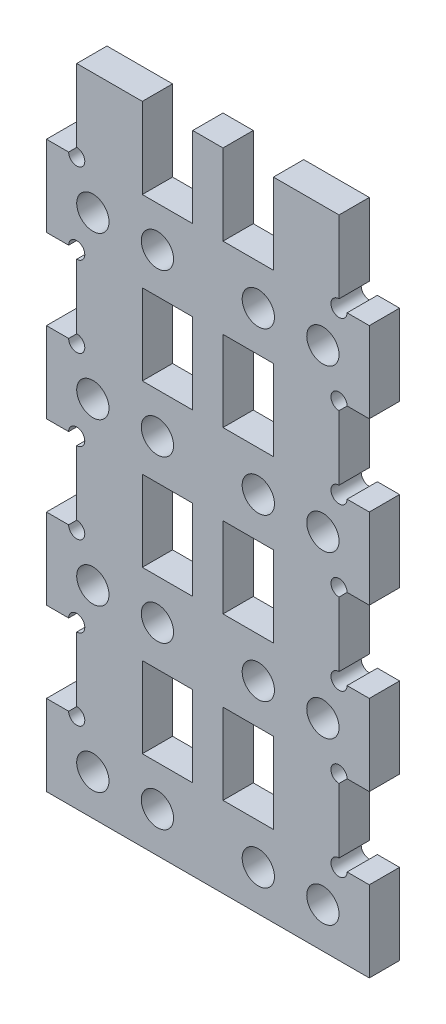
from build123d import *

# Parameters (mm, degrees)
EXTRUDE_1_DEPTH     = 3
SKETCH_2_W          = 5
SKETCH_2_H          = 8
CUT_EXTRUDE_1_DEPTH = 3
SKETCH_3_R          = 1.6
CUT_EXTRUDE_2_DEPTH = 3
CUT_EXTRUDE_3_REACH = 5
SKETCH_5_R          = 1.6
CUT_EXTRUDE_4_REACH = 5
SKETCH_6_R          = 0.8


with BuildPart() as part:
    # 草图1 → 凸台-拉伸1 (new body)
    with BuildSketch(Plane.XY):
        Polygon((16, 0), (-16, 0), (-16, 8), (-13, 8), (-13, 16), (-16, 16), (-16, 24), (-13, 24), (-13, 32), (-16, 32), (-16, 40), (-13, 40), (-13, 48), (-16, 48), (-16, 56), (-13, 56), (-13, 64), (13, 64), (13, 56), (16, 56), (16, 48), (13, 48), (13, 40), (16, 40), (16, 32), (13, 32), (13, 24), (16, 24), (16, 16), (13, 16), (13, 8), (16, 8), align=None)
    extrude(amount=EXTRUDE_1_DEPTH)

    # 草图2 → 切除-拉伸1 (cut)
    with BuildSketch(Plane.XY.offset(3)):
        with Locations((-4, 28)):
            Rectangle(SKETCH_2_W, SKETCH_2_H)
        with Locations((-4, 12)):
            Rectangle(SKETCH_2_W, SKETCH_2_H)
        with Locations((4, 28)):
            Rectangle(SKETCH_2_W, SKETCH_2_H)
        with Locations((-4, 44)):
            Rectangle(SKETCH_2_W, SKETCH_2_H)
        with Locations((4, 44)):
            Rectangle(SKETCH_2_W, SKETCH_2_H)
        with Locations((4, 12)):
            Rectangle(SKETCH_2_W, SKETCH_2_H)
        with Locations((4, 60)):
            Rectangle(SKETCH_2_W, SKETCH_2_H)
        with Locations((-4, 60)):
            Rectangle(SKETCH_2_W, SKETCH_2_H)
    extrude(amount=-CUT_EXTRUDE_1_DEPTH, mode=Mode.SUBTRACT)

    # 草图3 → 切除-拉伸2 (cut)
    with BuildSketch(Plane.XY.offset(3)):
        with Locations((-11.4, 4)):
            Circle(SKETCH_3_R)
        with Locations((11.4, 4)):
            Circle(SKETCH_3_R)
        with Locations((-11.4, 20)):
            Circle(SKETCH_3_R)
        with Locations((11.4, 20)):
            Circle(SKETCH_3_R)
        with Locations((-11.4, 36)):
            Circle(SKETCH_3_R)
        with Locations((11.4, 36)):
            Circle(SKETCH_3_R)
        with Locations((-11.4, 52)):
            Circle(SKETCH_3_R)
        with Locations((11.4, 52)):
            Circle(SKETCH_3_R)
    extrude(amount=-CUT_EXTRUDE_2_DEPTH, mode=Mode.SUBTRACT)

    # 草图5 → 切除-拉伸3 (cut, up to next)
    with BuildSketch(Plane.XY.offset(3), mode=Mode.PRIVATE) as cut_extrude_3_sk1:
        with Locations((-5, 4)):
            Circle(SKETCH_5_R)
    cut_extrude_3_tool1 = extrude(cut_extrude_3_sk1.sketch, amount=-CUT_EXTRUDE_3_REACH, mode=Mode.PRIVATE) & part.part
    add(cut_extrude_3_tool1.solids().sort_by_distance((-5, 4, 3))[0], mode=Mode.SUBTRACT)
    # 草图5 → 切除-拉伸3 (cut, up to next)
    with BuildSketch(Plane.XY.offset(3), mode=Mode.PRIVATE) as cut_extrude_3_sk2:
        with Locations((5, 4)):
            Circle(SKETCH_5_R)
    cut_extrude_3_tool2 = extrude(cut_extrude_3_sk2.sketch, amount=-CUT_EXTRUDE_3_REACH, mode=Mode.PRIVATE) & part.part
    add(cut_extrude_3_tool2.solids().sort_by_distance((5, 4, 3))[0], mode=Mode.SUBTRACT)
    # 草图5 → 切除-拉伸3 (cut, up to next)
    with BuildSketch(Plane.XY.offset(3), mode=Mode.PRIVATE) as cut_extrude_3_sk3:
        with Locations((-5, 20)):
            Circle(SKETCH_5_R)
    cut_extrude_3_tool3 = extrude(cut_extrude_3_sk3.sketch, amount=-CUT_EXTRUDE_3_REACH, mode=Mode.PRIVATE) & part.part
    add(cut_extrude_3_tool3.solids().sort_by_distance((-5, 20, 3))[0], mode=Mode.SUBTRACT)
    # 草图5 → 切除-拉伸3 (cut, up to next)
    with BuildSketch(Plane.XY.offset(3), mode=Mode.PRIVATE) as cut_extrude_3_sk4:
        with Locations((5, 20)):
            Circle(SKETCH_5_R)
    cut_extrude_3_tool4 = extrude(cut_extrude_3_sk4.sketch, amount=-CUT_EXTRUDE_3_REACH, mode=Mode.PRIVATE) & part.part
    add(cut_extrude_3_tool4.solids().sort_by_distance((5, 20, 3))[0], mode=Mode.SUBTRACT)
    # 草图5 → 切除-拉伸3 (cut, up to next)
    with BuildSketch(Plane.XY.offset(3), mode=Mode.PRIVATE) as cut_extrude_3_sk5:
        with Locations((-5, 36)):
            Circle(SKETCH_5_R)
    cut_extrude_3_tool5 = extrude(cut_extrude_3_sk5.sketch, amount=-CUT_EXTRUDE_3_REACH, mode=Mode.PRIVATE) & part.part
    add(cut_extrude_3_tool5.solids().sort_by_distance((-5, 36, 3))[0], mode=Mode.SUBTRACT)
    # 草图5 → 切除-拉伸3 (cut, up to next)
    with BuildSketch(Plane.XY.offset(3), mode=Mode.PRIVATE) as cut_extrude_3_sk6:
        with Locations((5, 36)):
            Circle(SKETCH_5_R)
    cut_extrude_3_tool6 = extrude(cut_extrude_3_sk6.sketch, amount=-CUT_EXTRUDE_3_REACH, mode=Mode.PRIVATE) & part.part
    add(cut_extrude_3_tool6.solids().sort_by_distance((5, 36, 3))[0], mode=Mode.SUBTRACT)
    # 草图5 → 切除-拉伸3 (cut, up to next)
    with BuildSketch(Plane.XY.offset(3), mode=Mode.PRIVATE) as cut_extrude_3_sk7:
        with Locations((-5, 52)):
            Circle(SKETCH_5_R)
    cut_extrude_3_tool7 = extrude(cut_extrude_3_sk7.sketch, amount=-CUT_EXTRUDE_3_REACH, mode=Mode.PRIVATE) & part.part
    add(cut_extrude_3_tool7.solids().sort_by_distance((-5, 52, 3))[0], mode=Mode.SUBTRACT)
    # 草图5 → 切除-拉伸3 (cut, up to next)
    with BuildSketch(Plane.XY.offset(3), mode=Mode.PRIVATE) as cut_extrude_3_sk8:
        with Locations((5, 52)):
            Circle(SKETCH_5_R)
    cut_extrude_3_tool8 = extrude(cut_extrude_3_sk8.sketch, amount=-CUT_EXTRUDE_3_REACH, mode=Mode.PRIVATE) & part.part
    add(cut_extrude_3_tool8.solids().sort_by_distance((5, 52, 3))[0], mode=Mode.SUBTRACT)

    # 草图6 → 切除-拉伸4 (cut, up to next)
    with BuildSketch(Plane.XY.offset(3), mode=Mode.PRIVATE) as cut_extrude_4_sk1:
        with Locations((-13, 8)):
            Circle(SKETCH_6_R)
    cut_extrude_4_tool1 = extrude(cut_extrude_4_sk1.sketch, amount=-CUT_EXTRUDE_4_REACH, mode=Mode.PRIVATE) & part.part
    add(cut_extrude_4_tool1.solids().sort_by_distance((-13, 8, 3))[0], mode=Mode.SUBTRACT)
    # 草图6 → 切除-拉伸4 (cut, up to next)
    with BuildSketch(Plane.XY.offset(3), mode=Mode.PRIVATE) as cut_extrude_4_sk2:
        with Locations((-13, 16)):
            Circle(SKETCH_6_R)
    cut_extrude_4_tool2 = extrude(cut_extrude_4_sk2.sketch, amount=-CUT_EXTRUDE_4_REACH, mode=Mode.PRIVATE) & part.part
    add(cut_extrude_4_tool2.solids().sort_by_distance((-13, 16, 3))[0], mode=Mode.SUBTRACT)
    # 草图6 → 切除-拉伸4 (cut, up to next)
    with BuildSketch(Plane.XY.offset(3), mode=Mode.PRIVATE) as cut_extrude_4_sk3:
        with Locations((-13, 24)):
            Circle(SKETCH_6_R)
    cut_extrude_4_tool3 = extrude(cut_extrude_4_sk3.sketch, amount=-CUT_EXTRUDE_4_REACH, mode=Mode.PRIVATE) & part.part
    add(cut_extrude_4_tool3.solids().sort_by_distance((-13, 24, 3))[0], mode=Mode.SUBTRACT)
    # 草图6 → 切除-拉伸4 (cut, up to next)
    with BuildSketch(Plane.XY.offset(3), mode=Mode.PRIVATE) as cut_extrude_4_sk4:
        with Locations((-13, 32)):
            Circle(SKETCH_6_R)
    cut_extrude_4_tool4 = extrude(cut_extrude_4_sk4.sketch, amount=-CUT_EXTRUDE_4_REACH, mode=Mode.PRIVATE) & part.part
    add(cut_extrude_4_tool4.solids().sort_by_distance((-13, 32, 3))[0], mode=Mode.SUBTRACT)
    # 草图6 → 切除-拉伸4 (cut, up to next)
    with BuildSketch(Plane.XY.offset(3), mode=Mode.PRIVATE) as cut_extrude_4_sk5:
        with Locations((-13, 40)):
            Circle(SKETCH_6_R)
    cut_extrude_4_tool5 = extrude(cut_extrude_4_sk5.sketch, amount=-CUT_EXTRUDE_4_REACH, mode=Mode.PRIVATE) & part.part
    add(cut_extrude_4_tool5.solids().sort_by_distance((-13, 40, 3))[0], mode=Mode.SUBTRACT)
    # 草图6 → 切除-拉伸4 (cut, up to next)
    with BuildSketch(Plane.XY.offset(3), mode=Mode.PRIVATE) as cut_extrude_4_sk6:
        with Locations((-13, 48)):
            Circle(SKETCH_6_R)
    cut_extrude_4_tool6 = extrude(cut_extrude_4_sk6.sketch, amount=-CUT_EXTRUDE_4_REACH, mode=Mode.PRIVATE) & part.part
    add(cut_extrude_4_tool6.solids().sort_by_distance((-13, 48, 3))[0], mode=Mode.SUBTRACT)
    # 草图6 → 切除-拉伸4 (cut, up to next)
    with BuildSketch(Plane.XY.offset(3), mode=Mode.PRIVATE) as cut_extrude_4_sk7:
        with Locations((-13, 56)):
            Circle(SKETCH_6_R)
    cut_extrude_4_tool7 = extrude(cut_extrude_4_sk7.sketch, amount=-CUT_EXTRUDE_4_REACH, mode=Mode.PRIVATE) & part.part
    add(cut_extrude_4_tool7.solids().sort_by_distance((-13, 56, 3))[0], mode=Mode.SUBTRACT)
    # 草图6 → 切除-拉伸4 (cut, up to next)
    with BuildSketch(Plane.XY.offset(3), mode=Mode.PRIVATE) as cut_extrude_4_sk8:
        with Locations((13, 8)):
            Circle(SKETCH_6_R)
    cut_extrude_4_tool8 = extrude(cut_extrude_4_sk8.sketch, amount=-CUT_EXTRUDE_4_REACH, mode=Mode.PRIVATE) & part.part
    add(cut_extrude_4_tool8.solids().sort_by_distance((13, 8, 3))[0], mode=Mode.SUBTRACT)
    # 草图6 → 切除-拉伸4 (cut, up to next)
    with BuildSketch(Plane.XY.offset(3), mode=Mode.PRIVATE) as cut_extrude_4_sk9:
        with Locations((13, 16)):
            Circle(SKETCH_6_R)
    cut_extrude_4_tool9 = extrude(cut_extrude_4_sk9.sketch, amount=-CUT_EXTRUDE_4_REACH, mode=Mode.PRIVATE) & part.part
    add(cut_extrude_4_tool9.solids().sort_by_distance((13, 16, 3))[0], mode=Mode.SUBTRACT)
    # 草图6 → 切除-拉伸4 (cut, up to next)
    with BuildSketch(Plane.XY.offset(3), mode=Mode.PRIVATE) as cut_extrude_4_sk10:
        with Locations((13, 24)):
            Circle(SKETCH_6_R)
    cut_extrude_4_tool10 = extrude(cut_extrude_4_sk10.sketch, amount=-CUT_EXTRUDE_4_REACH, mode=Mode.PRIVATE) & part.part
    add(cut_extrude_4_tool10.solids().sort_by_distance((13, 24, 3))[0], mode=Mode.SUBTRACT)
    # 草图6 → 切除-拉伸4 (cut, up to next)
    with BuildSketch(Plane.XY.offset(3), mode=Mode.PRIVATE) as cut_extrude_4_sk11:
        with Locations((13, 32)):
            Circle(SKETCH_6_R)
    cut_extrude_4_tool11 = extrude(cut_extrude_4_sk11.sketch, amount=-CUT_EXTRUDE_4_REACH, mode=Mode.PRIVATE) & part.part
    add(cut_extrude_4_tool11.solids().sort_by_distance((13, 32, 3))[0], mode=Mode.SUBTRACT)
    # 草图6 → 切除-拉伸4 (cut, up to next)
    with BuildSketch(Plane.XY.offset(3), mode=Mode.PRIVATE) as cut_extrude_4_sk12:
        with Locations((13, 40)):
            Circle(SKETCH_6_R)
    cut_extrude_4_tool12 = extrude(cut_extrude_4_sk12.sketch, amount=-CUT_EXTRUDE_4_REACH, mode=Mode.PRIVATE) & part.part
    add(cut_extrude_4_tool12.solids().sort_by_distance((13, 40, 3))[0], mode=Mode.SUBTRACT)
    # 草图6 → 切除-拉伸4 (cut, up to next)
    with BuildSketch(Plane.XY.offset(3), mode=Mode.PRIVATE) as cut_extrude_4_sk13:
        with Locations((13, 48)):
            Circle(SKETCH_6_R)
    cut_extrude_4_tool13 = extrude(cut_extrude_4_sk13.sketch, amount=-CUT_EXTRUDE_4_REACH, mode=Mode.PRIVATE) & part.part
    add(cut_extrude_4_tool13.solids().sort_by_distance((13, 48, 3))[0], mode=Mode.SUBTRACT)
    # 草图6 → 切除-拉伸4 (cut, up to next)
    with BuildSketch(Plane.XY.offset(3), mode=Mode.PRIVATE) as cut_extrude_4_sk14:
        with Locations((13, 56)):
            Circle(SKETCH_6_R)
    cut_extrude_4_tool14 = extrude(cut_extrude_4_sk14.sketch, amount=-CUT_EXTRUDE_4_REACH, mode=Mode.PRIVATE) & part.part
    add(cut_extrude_4_tool14.solids().sort_by_distance((13, 56, 3))[0], mode=Mode.SUBTRACT)


solid = part.part
